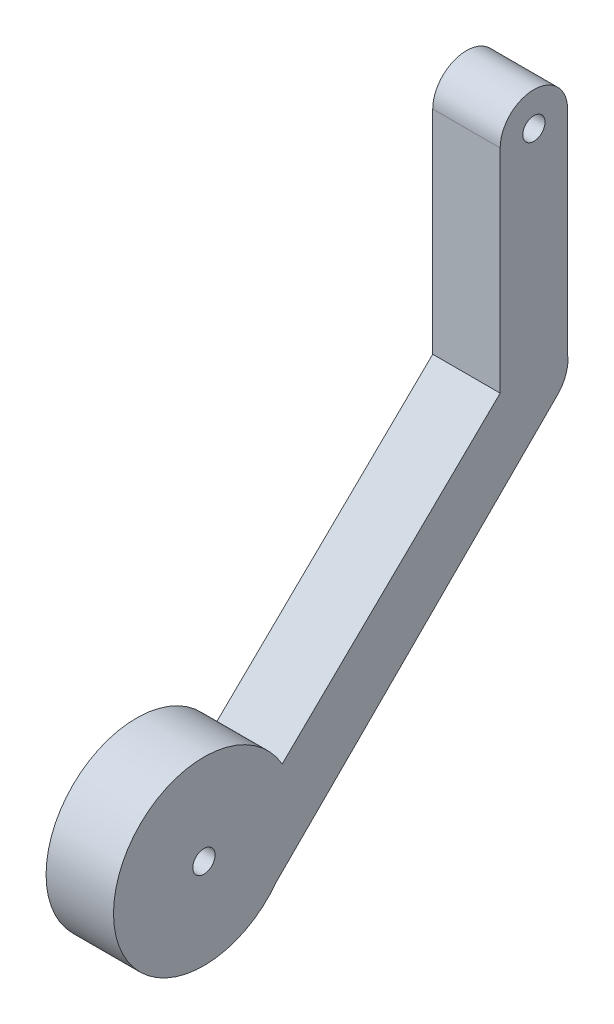
from build123d import *

# Parameters (mm, degrees)
SKETCH_1_R      = 1.65
EXTRUDE_1_DEPTH = 10


with BuildPart() as part:
    # 草图1 → 凸台-拉伸1 (new body)
    with BuildSketch(Plane(origin=(56.415924247, 0, 0), x_dir=(0, 0, -1), z_dir=(1, 0, 0))):
        with BuildLine():
            Line((-55.264392442, -53.153642626), (-87.583702197, -84.606168615))
            ThreePointArc((-87.583702197, -84.606168615), (-112.572118878, -90.553138734), (-88.412490375, -99.276657086))
            Line((-88.412490375, -99.276657086), (-46.780021188, -57.644187899))
            ThreePointArc((-46.780021188, -57.644187899), (-45.496623318, -55.576307852), (-45.264392442, -53.153642626))
            Line((-45.264392442, -53.153642626), (-45.264392442, -21.663090289))
            ThreePointArc((-45.264392442, -21.663090289), (-50.264392442, -16.663090289), (-55.264392442, -21.663090289))
            Line((-55.264392442, -21.663090289), (-55.264392442, -53.153642626))
        make_face()
        with Locations((-50.264392442, -21.663090289)):
            Circle(SKETCH_1_R, mode=Mode.SUBTRACT)
        with Locations((-99.19033753, -91.309123254)):
            Circle(SKETCH_1_R, mode=Mode.SUBTRACT)
    extrude(amount=EXTRUDE_1_DEPTH)


solid = part.part
